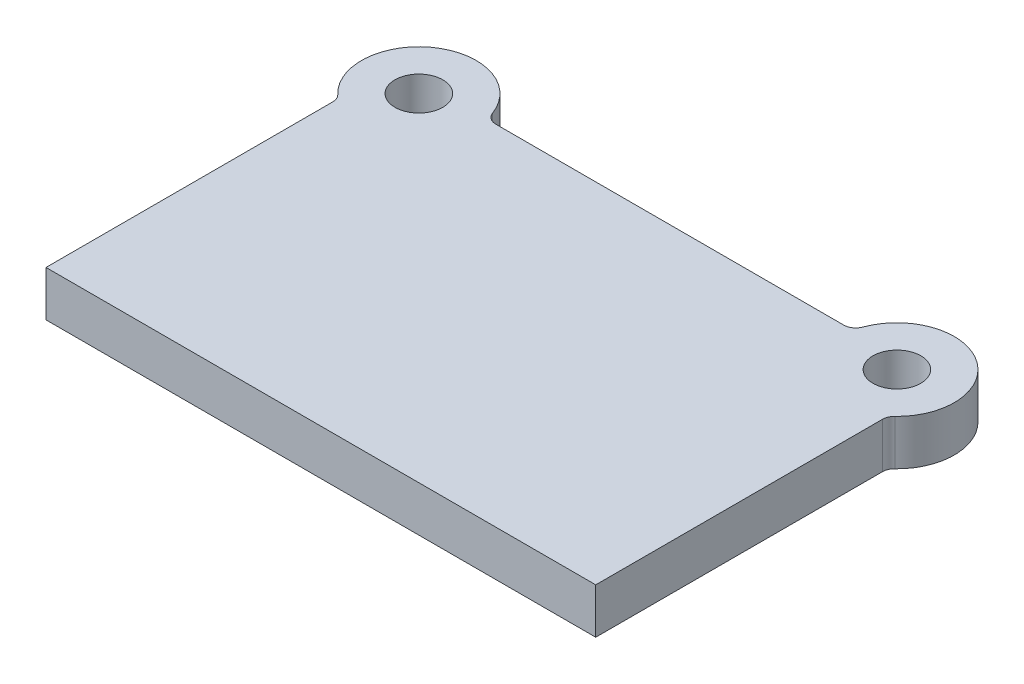
from build123d import *

# Parameters (mm, degrees)
SKETCH1_R           = 20
BOSS_EXTRUDE1_DEPTH = 38
FILLET1_R           = 10


with BuildPart() as part:
    # Sketch1 → Boss-Extrude1 (new body)
    with BuildSketch(Plane(origin=(0, 0, 0), x_dir=(1, 0, 0), z_dir=(0, 1, 0))):
        with BuildLine():
            Line((230, 0), (-230, 0))
            Line((-230, 0), (-230, 244.53001201))
            ThreePointArc((-230, 244.53001201), (-225.20214801, 322.851581802), (-153.053221623, 292))
            Line((-153.053221623, 292), (153.053221623, 292))
            ThreePointArc((153.053221623, 292), (225.20214801, 322.851581802), (230, 244.53001201))
            Line((230, 244.53001201), (230, 0))
        make_face()
        with Locations((-200, 282)):
            Circle(SKETCH1_R, mode=Mode.SUBTRACT)
        with Locations((200, 282)):
            Circle(SKETCH1_R, mode=Mode.SUBTRACT)
    extrude(amount=BOSS_EXTRUDE1_DEPTH)

    # Fillet1
    fillet1_edges = [part.edges().sort_by_distance(p)[0] for p in [
        (-230, 19, -244.53001201),
        (-153.053221623, 19, -292),
        (153.053221623, 19, -292),
        (230, 19, -244.53001201),
    ]]
    fillet(fillet1_edges, radius=FILLET1_R)


solid = part.part
